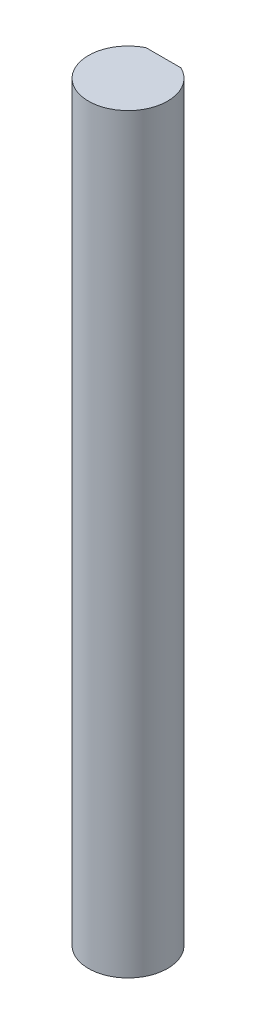
from build123d import *

# Parameters (mm, degrees)
BOSS_EXTRUDE1_DEPTH = 45


with BuildPart() as part:
    # Sketch1 → Boss-Extrude1 (new body)
    with BuildSketch(Plane(origin=(0, 0, 0), x_dir=(1, 0, 0), z_dir=(0, 1, 0))):
        with BuildLine():
            Line((-1.046432694, 2.128330957), (1.046432694, 2.128330957))
            ThreePointArc((1.046432694, 2.128330957), (0, -2.371669043), (-1.046432694, 2.128330957))
        make_face()
    extrude(amount=BOSS_EXTRUDE1_DEPTH)


solid = part.part
